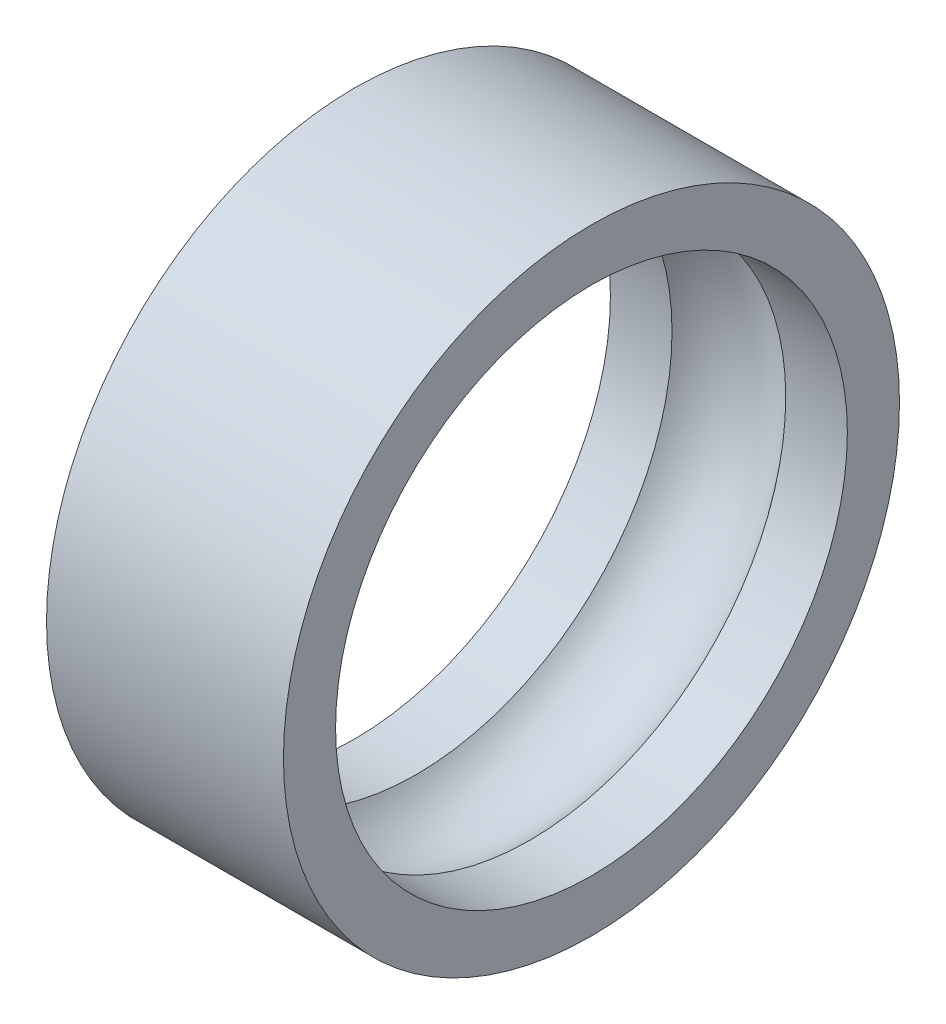
from build123d import *


with BuildPart() as part:
    # Çizim2 → Döndür1 (revolve)
    with BuildSketch(Plane.XY):
        with BuildLine():
            Line((-2.5, 6.5), (2.5, 6.5))
            Line((2.5, 6.5), (2.5, 5.4))
            Line((2.5, 5.4), (1.2, 5.4))
            ThreePointArc((1.2, 5.4), (0, 6), (-1.2, 5.4))
            Line((-1.2, 5.4), (-2.5, 5.4))
            Line((-2.5, 5.4), (-2.5, 6.5))
        make_face()
    revolve(axis=Axis((0, 0, 0), (-1, 0, 0)))


solid = part.part
